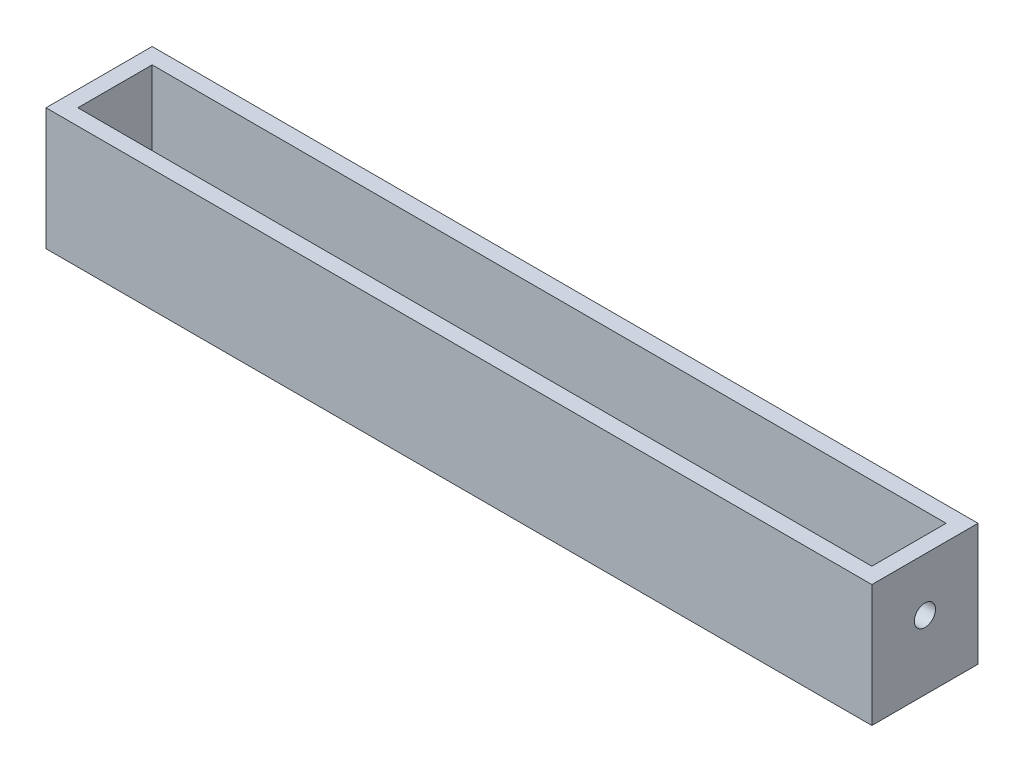
from build123d import *

# Parameters (mm, degrees)
SKETCH_1_W          = 155.6
SKETCH_1_H          = 20
SKETCH_1_R          = 4
EXTRUDE_1_DEPTH     = 3
SKETCH_2_W          = 155.6
SKETCH_2_H          = 20
SKETCH_2_W_2        = 149.6
SKETCH_2_H_2        = 14
EXTRUDE_2_DEPTH     = 20
SKETCH_3_R          = 2
CUT_EXTRUDE_1_DEPTH = 160


with BuildPart() as part:
    # 草图1 → 凸台-拉伸1 (new body)
    with BuildSketch(Plane(origin=(0, 0, 0), x_dir=(1, 0, 0), z_dir=(0, 1, 0))):
        Rectangle(SKETCH_1_W, SKETCH_1_H)
        with Locations((-37.5, 0)):
            Circle(SKETCH_1_R, mode=Mode.SUBTRACT)
        with Locations((37.5, 0)):
            Circle(SKETCH_1_R, mode=Mode.SUBTRACT)
    extrude(amount=EXTRUDE_1_DEPTH)

    # 草图2 → 凸台-拉伸2 (add)
    with BuildSketch(Plane(origin=(0, 3, 0), x_dir=(1, 0, 0), z_dir=(0, 1, 0))):
        Rectangle(SKETCH_2_W, SKETCH_2_H)
        Rectangle(SKETCH_2_W_2, SKETCH_2_H_2, mode=Mode.SUBTRACT)
    extrude(amount=EXTRUDE_2_DEPTH)

    # 草图3 → 切除-拉伸1 (cut)
    with BuildSketch(Plane.ZY.offset(77.8)):
        with Locations((0, 13)):
            Circle(SKETCH_3_R)
    extrude(amount=-CUT_EXTRUDE_1_DEPTH, mode=Mode.SUBTRACT)


solid = part.part
